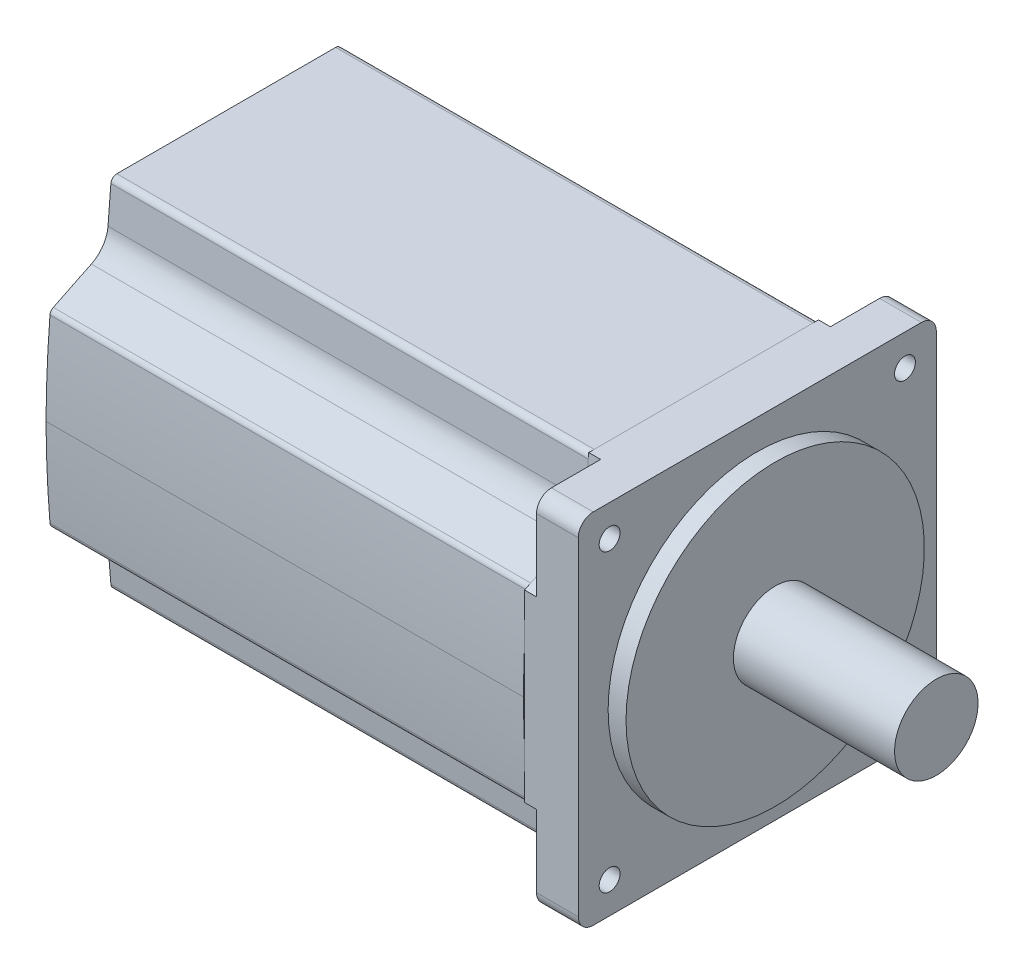
from build123d import *

# Parameters (mm, degrees)
BOSS_EXTRUDE3_DEPTH                 = 80
SKETCH9_W                           = 60
SKETCH9_H                           = 60
BOSS_EXTRUDE4_DEPTH                 = 9
CUT_EXTRUDE1_DEPTH                  = 2
SKETCH10_W                          = 1.75
SKETCH10_H                          = 7
F_3_5_3_5_DIAMETER_HOLE1_AT_2_COUNT = 2
F_3_5_3_5_DIAMETER_HOLE1_AT_2_PITCH = 49.497474683
F_3_5_3_5_DIAMETER_HOLE1_AT_3_COUNT = 2
F_3_5_3_5_DIAMETER_HOLE1_AT_3_PITCH = 49.497474683
F_3_5_3_5_DIAMETER_HOLE1_AT_4_COUNT = 2
F_3_5_3_5_DIAMETER_HOLE1_AT_4_PITCH = 70
FILLET2_R                           = 2.5


with BuildPart() as part:
    # Sketch7 → Boss-Extrude3 (new body)
    with BuildSketch(Plane(origin=(0, 0, 0), x_dir=(0, 0, -1), z_dir=(1, 0, 0))):
        with BuildLine():
            Line((-18.33259, -30), (18.33259, -30))
            ThreePointArc((18.33259, -30), (19.010683209, -29.734975918), (19.329354357, -29.0803792))
            Line((19.329354357, -29.0803792), (19.809736411, -23.123269525))
            ThreePointArc((19.809736411, -23.123269525), (20.663321526, -20.707161793), (22.60170242, -19.031195315))
            Line((22.60170242, -19.031195315), (28.976894141, -15.921806476))
            ThreePointArc((28.976894141, -15.921806476), (29.364202593, -15.587151765), (29.535181656, -15.104691639))
            ThreePointArc((29.535181656, -15.104691639), (30.010346531, -7.558626197), (30.200228925, 0))
            ThreePointArc((30.200228925, 0), (30.010346531, 7.558626197), (29.535181656, 15.104691639))
            ThreePointArc((29.535181656, 15.104691639), (29.364202593, 15.587151765), (28.976894141, 15.921806476))
            Line((28.976894141, 15.921806476), (22.60170242, 19.031195315))
            ThreePointArc((22.60170242, 19.031195315), (20.663321526, 20.707161793), (19.809736411, 23.123269525))
            Line((19.809736411, 23.123269525), (19.329354357, 29.0803792))
            ThreePointArc((19.329354357, 29.0803792), (19.010683209, 29.734975918), (18.33259, 30))
            Line((18.33259, 30), (-18.33259, 30))
            ThreePointArc((-18.33259, 30), (-19.010683209, 29.734975918), (-19.329354357, 29.0803792))
            Line((-19.329354357, 29.0803792), (-19.809736411, 23.123269525))
            ThreePointArc((-19.809736411, 23.123269525), (-20.663321526, 20.707161793), (-22.60170242, 19.031195315))
            Line((-22.60170242, 19.031195315), (-28.976894141, 15.921806476))
            ThreePointArc((-28.976894141, 15.921806476), (-29.364202593, 15.587151765), (-29.535181656, 15.104691639))
            ThreePointArc((-29.535181656, 15.104691639), (-30.010346531, 7.558626197), (-30.200228925, 0))
            ThreePointArc((-30.200228925, 0), (-30.010346531, -7.558626197), (-29.535181656, -15.104691639))
            ThreePointArc((-29.535181656, -15.104691639), (-29.364202593, -15.587151765), (-28.976894141, -15.921806476))
            Line((-28.976894141, -15.921806476), (-22.60170242, -19.031195315))
            ThreePointArc((-22.60170242, -19.031195315), (-20.663321526, -20.707161793), (-19.809736411, -23.123269525))
            Line((-19.809736411, -23.123269525), (-19.329354357, -29.0803792))
            ThreePointArc((-19.329354357, -29.0803792), (-19.010683209, -29.734975918), (-18.33259, -30))
        make_face()
    extrude(amount=-BOSS_EXTRUDE3_DEPTH)


with BuildPart() as body_2:
    # Sketch9 → Boss-Extrude4 (new body)
    with BuildSketch(Plane(origin=(0, 0, 0), x_dir=(0, 0, -1), z_dir=(1, 0, 0))):
        Rectangle(SKETCH9_W, SKETCH9_H)
    extrude(amount=BOSS_EXTRUDE4_DEPTH)

    # Sketch12 → Cut-Extrude1 (cut)
    with BuildSketch(Plane.ZY):
        with BuildLine():
            Line((-28.976894141, 15.921806476), (-22.60170242, 19.031195315))
            ThreePointArc((-22.60170242, 19.031195315), (-20.663321526, 20.707161793), (-19.809736411, 23.123269525))
            Line((-19.809736411, 23.123269525), (-19.329354357, 29.0803792))
            Line((-19.329354357, 29.0803792), (-19.255196023, 30))
            Line((-19.255196023, 30), (-30, 30))
            Line((-30, 30), (-30, 15.422804394))
            Line((-30, 15.422804394), (-28.976894141, 15.921806476))
        make_face()
        with BuildLine():
            Line((19.329354357, 29.0803792), (19.809736411, 23.123269525))
            ThreePointArc((19.809736411, 23.123269525), (20.663321526, 20.707161793), (22.60170242, 19.031195315))
            Line((22.60170242, 19.031195315), (28.976894141, 15.921806476))
            Line((28.976894141, 15.921806476), (30, 15.422804394))
            Line((30, 15.422804394), (30, 30))
            Line((30, 30), (19.255196023, 30))
            Line((19.255196023, 30), (19.329354357, 29.0803792))
        make_face()
        with BuildLine():
            Line((-22.60170242, -19.031195315), (-28.976894141, -15.921806476))
            Line((-28.976894141, -15.921806476), (-30, -15.422804394))
            Line((-30, -15.422804394), (-30, -30))
            Line((-30, -30), (-19.255196023, -30))
            Line((-19.255196023, -30), (-19.329354357, -29.0803792))
            Line((-19.329354357, -29.0803792), (-19.809736411, -23.123269525))
            ThreePointArc((-19.809736411, -23.123269525), (-20.663321526, -20.707161793), (-22.60170242, -19.031195315))
        make_face()
        with BuildLine():
            Line((19.809736411, -23.123269525), (19.329354357, -29.0803792))
            Line((19.329354357, -29.0803792), (19.255196023, -30))
            Line((19.255196023, -30), (30, -30))
            Line((30, -30), (30, -15.422804394))
            Line((30, -15.422804394), (28.976894141, -15.921806476))
            Line((28.976894141, -15.921806476), (22.60170242, -19.031195315))
            ThreePointArc((22.60170242, -19.031195315), (20.663321526, -20.707161793), (19.809736411, -23.123269525))
        make_face()
    extrude(amount=-CUT_EXTRUDE1_DEPTH, mode=Mode.SUBTRACT)

    # Sketch10 → Ø3.5 (3.5) Diameter Hole1 (revolve, cut)
    with BuildSketch(Plane(origin=(9, 24.748737342, 24.748737342), x_dir=(0, 0, -1), z_dir=(0, 1, 0))):
        with Locations((0.875, 3.5)):
            Rectangle(SKETCH10_W, SKETCH10_H)
    f_3_5_3_5_diameter_hole1 = revolve(axis=Axis((15.35, 24.748737342, 24.748737342), (-1, 0, 0)), mode=Mode.SUBTRACT)

    # Ø3.5 (3.5) Diameter Hole1 at 2: Ø3.5 (3.5) Diameter Hole1 ×2
    with Locations(*[(0, 0, -i * F_3_5_3_5_DIAMETER_HOLE1_AT_2_PITCH) for i in range(1, F_3_5_3_5_DIAMETER_HOLE1_AT_2_COUNT)]):
        add(f_3_5_3_5_diameter_hole1, mode=Mode.SUBTRACT)

    # Ø3.5 (3.5) Diameter Hole1 at 3: Ø3.5 (3.5) Diameter Hole1 ×2
    with Locations(*[(0, -i * F_3_5_3_5_DIAMETER_HOLE1_AT_3_PITCH, 0) for i in range(1, F_3_5_3_5_DIAMETER_HOLE1_AT_3_COUNT)]):
        add(f_3_5_3_5_diameter_hole1, mode=Mode.SUBTRACT)

    # Ø3.5 (3.5) Diameter Hole1 at 4: Ø3.5 (3.5) Diameter Hole1 ×2
    with Locations(*[Vector(0, -0.707106781, -0.707106781) * (i * F_3_5_3_5_DIAMETER_HOLE1_AT_4_PITCH) for i in range(1, F_3_5_3_5_DIAMETER_HOLE1_AT_4_COUNT)]):
        add(f_3_5_3_5_diameter_hole1, mode=Mode.SUBTRACT)

    # Fillet2
    fillet2_edges = [body_2.edges().sort_by_distance(p)[0] for p in [
        (5.5, 30, 30),
        (5.5, 30, -30),
        (5.5, -30, -30),
        (5.5, -30, 30),
    ]]
    fillet(fillet2_edges, radius=FILLET2_R)


with BuildPart() as body_3:
    # Sketch8 → Revolve5 (revolve)
    with BuildSketch(Plane.XY):
        Polygon((39, 0), (39, 7), (12, 7), (12, 25), (9, 25), (9, 0), align=None)
    revolve(axis=Axis((-4.899761849, 0, 0), (1, 0, 0)))


solid = Compound([part.part, body_2.part, body_3.part])
